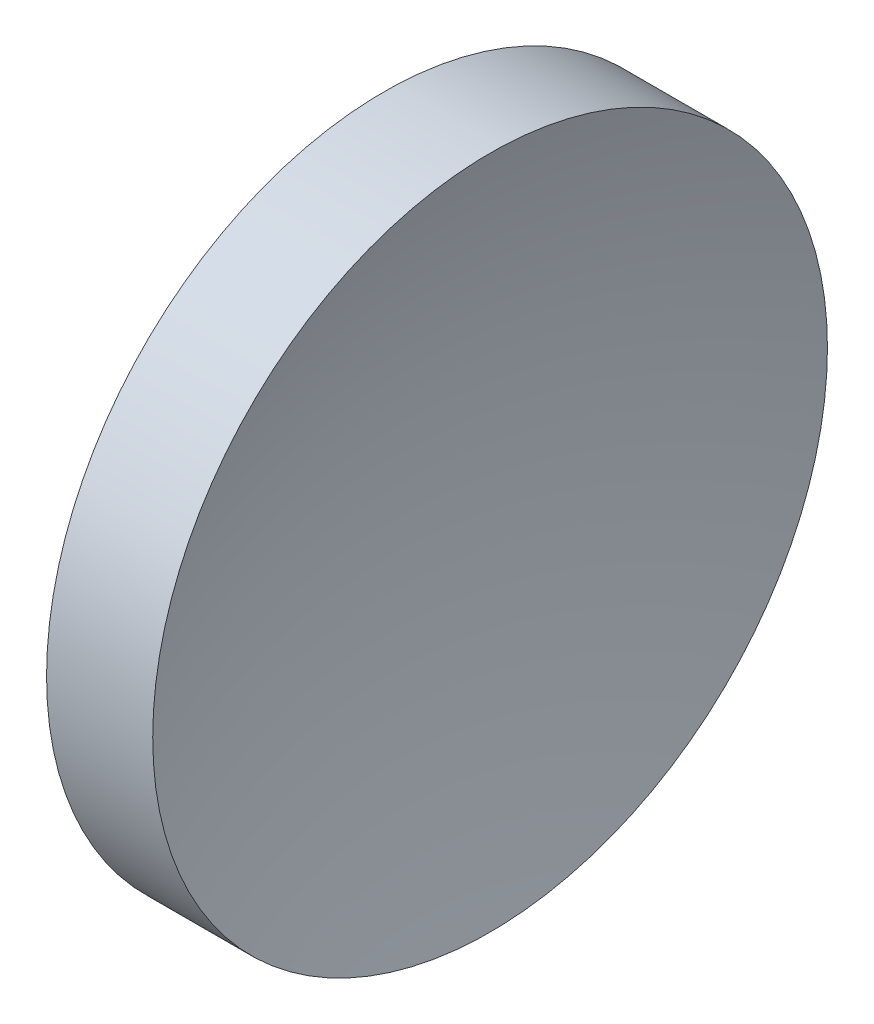
from build123d import *


with BuildPart() as part:
    # 草图1 → 旋转1 (revolve)
    with BuildSketch(Plane.XY, mode=Mode.PRIVATE) as revolve_1_sk:
        with BuildLine():
            Line((57.532337053, 32.610768129), (57.532337053, 45.110768129))
            Line((57.532337053, 45.110768129), (61.465727758, 45.110768129))
            ThreePointArc((61.465727758, 45.110768129), (60.017658745, 38.935222798), (59.532337053, 32.610768129))
            Line((59.532337053, 32.610768129), (57.532337053, 32.610768129))
        make_face()
    revolve(revolve_1_sk.sketch.rotate(Axis((56.10091508, 32.610768129, 0), (1, 0, 0)), 90), axis=Axis((56.10091508, 32.610768129, 0), (1, 0, 0)))  # turned: the seam where the file's is


solid = part.part
